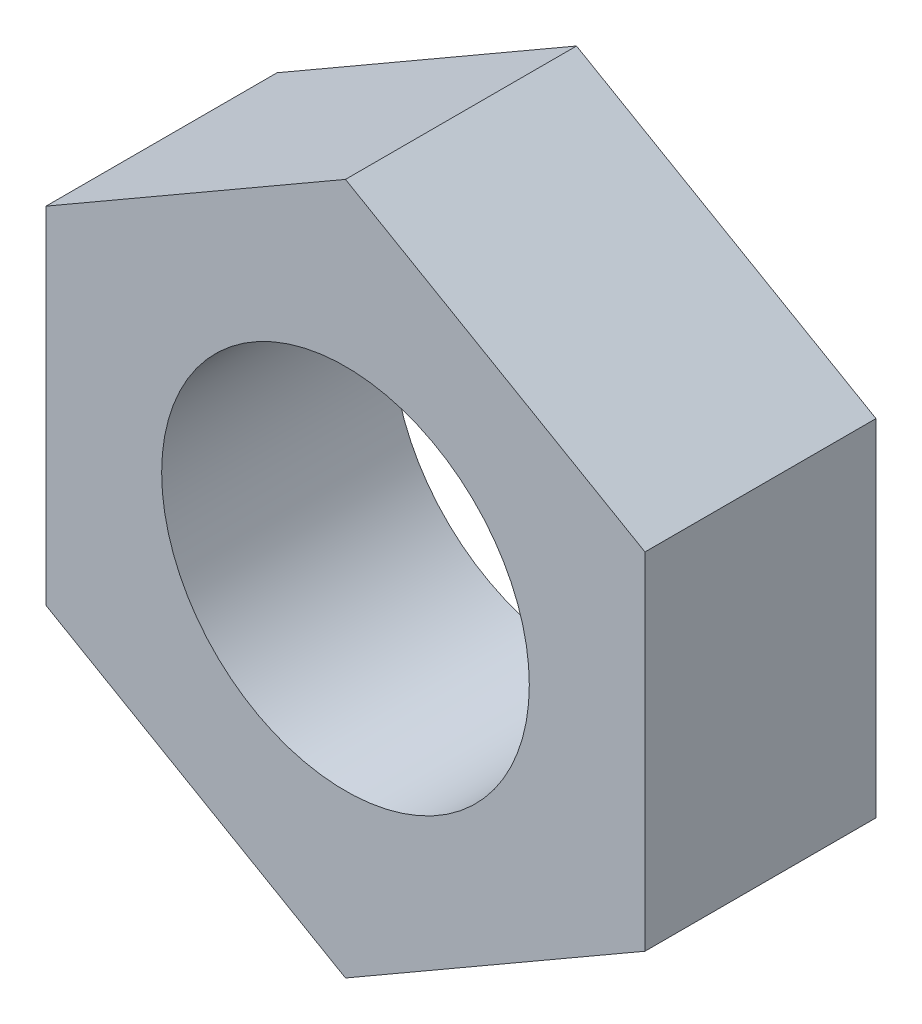
from build123d import *

# Parameters (mm, degrees)
SKETCH1_R      = 4.365625
EXTRUDE1_DEPTH = 5.4864


with BuildPart() as part:
    # Sketch1 → Extrude1 (new body)
    with BuildSketch(Plane.XY):
        Polygon((0, 8.212230229), (-7.112, 4.106115114), (-7.112, -4.106115114), (0, -8.212230229), (7.112, -4.106115114), (7.112, 4.106115114), align=None)
        Circle(SKETCH1_R, mode=Mode.SUBTRACT)
    extrude(amount=EXTRUDE1_DEPTH)


solid = part.part
